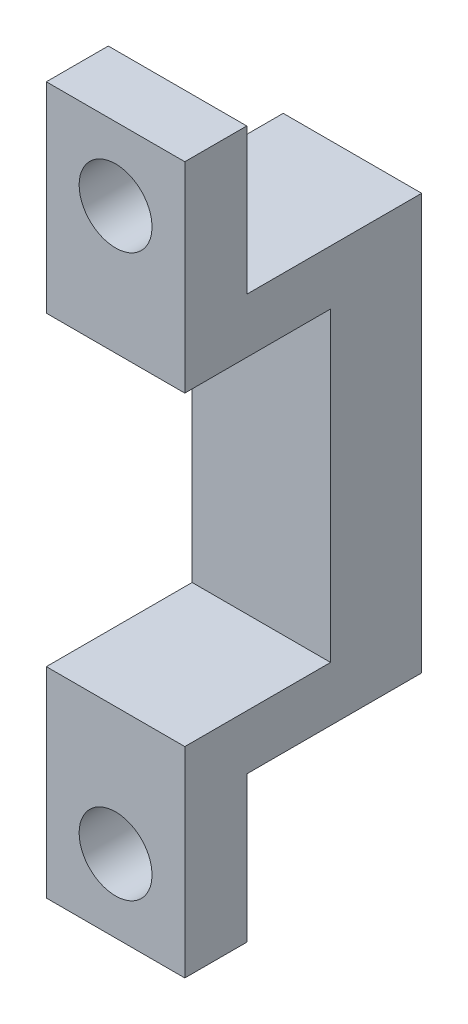
from build123d import *

# Parameters (mm, degrees)
SKETCH1_W           = 19
SKETCH1_H           = 57
BOSS_EXTRUDE1_DEPTH = 12.5
SKETCH2_W           = 19
SKETCH2_H           = 7.5
BOSS_EXTRUDE2_DEPTH = 20
SKETCH3_W           = 19
SKETCH3_H           = 8.5
BOSS_EXTRUDE3_DEPTH = 20
SKETCH4_W           = 19
SKETCH4_H           = 8.5
BOSS_EXTRUDE4_DEPTH = 20
SKETCH5_R           = 5
CUT_EXTRUDE1_DEPTH  = 20


with BuildPart() as part:
    # Sketch1 → Boss-Extrude1 (new body)
    with BuildSketch(Plane.XY):
        Rectangle(SKETCH1_W, SKETCH1_H)
    extrude(amount=BOSS_EXTRUDE1_DEPTH)

    # Sketch2 → Boss-Extrude2 (add)
    with BuildSketch(Plane.XY.offset(12.5)):
        with Locations((0, -24.75)):
            Rectangle(SKETCH2_W, SKETCH2_H)
        with Locations((0, 24.75)):
            Rectangle(SKETCH2_W, SKETCH2_H)
    extrude(amount=BOSS_EXTRUDE2_DEPTH)

    # Sketch3 → Boss-Extrude3 (add)
    with BuildSketch(Plane.XZ.offset(28.5)):
        with Locations((0, 28.25)):
            Rectangle(SKETCH3_W, SKETCH3_H)
    extrude(amount=BOSS_EXTRUDE3_DEPTH)

    # Sketch4 → Boss-Extrude4 (add)
    with BuildSketch(Plane(origin=(0, 28.5, 0), x_dir=(1, 0, 0), z_dir=(0, 1, 0))):
        with Locations((0, -28.25)):
            Rectangle(SKETCH4_W, SKETCH4_H)
    extrude(amount=BOSS_EXTRUDE4_DEPTH)

    # Sketch5 → Cut-Extrude1 (cut)
    with BuildSketch(Plane(origin=(0, 0, 24), x_dir=(-1, 0, 0), z_dir=(0, 0, -1))):
        with Locations((0, 38.5)):
            Circle(SKETCH5_R)
        with Locations((0, -38.5)):
            Circle(SKETCH5_R)
    extrude(amount=-CUT_EXTRUDE1_DEPTH, mode=Mode.SUBTRACT)


solid = part.part
